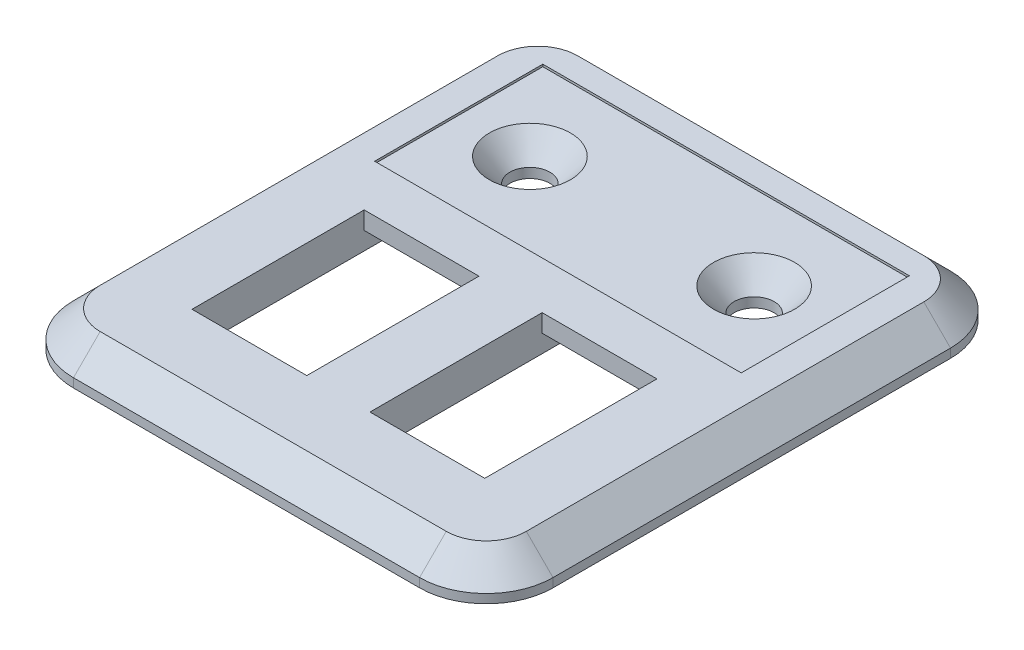
from build123d import *

# Parameters (mm, degrees)
SKETCH1_W                                     = 53.9
SKETCH1_H                                     = 59.675
SKETCH1_W_2                                   = 12.9
SKETCH1_H_2                                   = 19.35
BOSS_EXTRUDE1_DEPTH                           = 4
FILLET1_R                                     = 7.5
CHAMFER1_SIZE                                 = 3
CUT_EXTRUDE1_START                            = -2
SKETCH4_W                                     = 12.9
SKETCH4_H                                     = 24
CUT_EXTRUDE1_DEPTH                            = 3
SKETCH5_W                                     = 41.2
SKETCH5_H                                     = 18.9
CUT_EXTRUDE2_DEPTH                            = 0.25
CSK_FOR_8_FLAT_HEAD_SOCKET_CAP_SCREW1_A_COUNT = 2
CSK_FOR_8_FLAT_HEAD_SOCKET_CAP_SCREW1_A_PITCH = 25.2


with BuildPart() as part:
    # Sketch1 → Boss-Extrude1 (new body)
    with BuildSketch(Plane(origin=(0, 0, 0), x_dir=(1, 0, 0), z_dir=(0, 1, 0))):
        with Locations((0, 9.8375)):
            Rectangle(SKETCH1_W, SKETCH1_H)
        with Locations((10, 0)):
            Rectangle(SKETCH1_W_2, SKETCH1_H_2, mode=Mode.SUBTRACT)
        with Locations((-10, 0)):
            Rectangle(SKETCH1_W_2, SKETCH1_H_2, mode=Mode.SUBTRACT)
    extrude(amount=-BOSS_EXTRUDE1_DEPTH)

    # Fillet1
    fillet1_edges = [part.edges().sort_by_distance(p)[0] for p in [
        (26.95, -2, 20),
        (-26.95, -2, 20),
        (-26.95, -2, -39.675),
        (26.95, -2, -39.675),
    ]]
    fillet(fillet1_edges, radius=FILLET1_R)

    # Chamfer1
    chamfer1_edges = [part.edges().sort_by_distance(p)[0] for p in [
        (26.95, 0, -9.8375),
        (0, 0, -39.675),
        (-26.95, 0, -9.8375),
        (0, 0, 20),
        (-24.753300859, 0, 17.803300859),
        (24.753300859, 0, 17.803300859),
        (-24.753300859, 0, -37.478300859),
        (24.753300859, 0, -37.478300859),
    ]]
    chamfer(chamfer1_edges, length=CHAMFER1_SIZE)

    # Sketch4 → Cut-Extrude1 (cut, through all)
    with BuildSketch(Plane(origin=(0, 0, 0), x_dir=(1, 0, 0), z_dir=(0, 1, 0)).offset(CUT_EXTRUDE1_START)):
        with Locations((-10, 0)):
            Rectangle(SKETCH4_W, SKETCH4_H)
        with Locations((10, 0)):
            Rectangle(SKETCH4_W, SKETCH4_H)
    extrude(amount=-CUT_EXTRUDE1_DEPTH, mode=Mode.SUBTRACT)

    # Sketch5 → Cut-Extrude2 (cut)
    with BuildSketch(Plane(origin=(0, 0, 0), x_dir=(1, 0, 0), z_dir=(0, 1, 0))):
        with Locations((0, 24.45)):
            Rectangle(SKETCH5_W, SKETCH5_H)
    extrude(amount=-CUT_EXTRUDE2_DEPTH, mode=Mode.SUBTRACT)

    # Sketch3 → CSK for #8 Flat Head Socket Cap Screw1 (revolve, cut)
    with BuildSketch(Plane(origin=(-12.6, -0.25, -24.45), x_dir=(0, 0, 1), z_dir=(1, 0, 0))):
        Polygon((0, 0), (0, 3.75), (2.2479, 3.75), (2.2479, 2.658961536), (4.5593, 0), align=None)
    csk_for_8_flat_head_socket_cap_screw1 = revolve(axis=Axis((-12.6, 6.1, -24.45), (0, -1, 0)), mode=Mode.SUBTRACT)

    # CSK for #8 Flat Head Socket Cap Screw1 a: CSK for #8 Flat Head Socket Cap Screw1 ×2
    with Locations(*[(i * CSK_FOR_8_FLAT_HEAD_SOCKET_CAP_SCREW1_A_PITCH, 0, 0) for i in range(1, CSK_FOR_8_FLAT_HEAD_SOCKET_CAP_SCREW1_A_COUNT)]):
        add(csk_for_8_flat_head_socket_cap_screw1, mode=Mode.SUBTRACT)


solid = part.part
